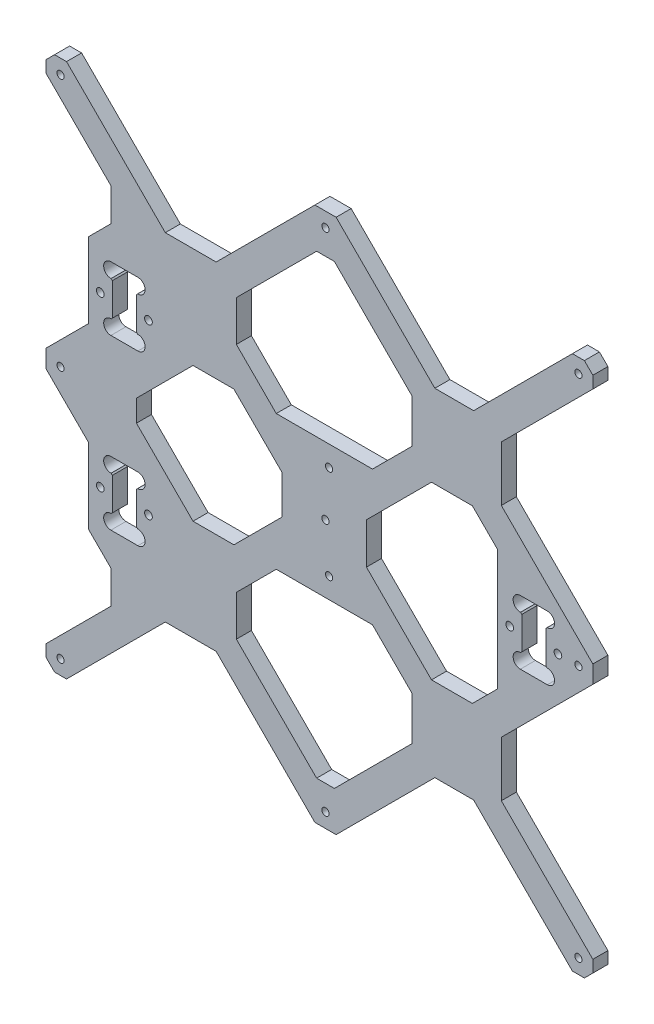
from build123d import *

# Parameters (mm, degrees)
MODEL_R             = 1.5
MODEL_R_2           = 1.6
BOSS_EXTRUDE1_DEPTH = 6.25


with BuildPart() as part:
    # Model → Boss-Extrude1 (new body)
    with BuildSketch(Plane.XY):
        Polygon((4.400116, 111), (45.400116, 70), (61.514718626, 70), (102.514718626, 111), (107.485169777, 111), (111, 107.485169777), (111, 102.514718626), (73, 64.514718626), (73, 41.666961), (111, 3.666961), (111, -3.666961), (73, -41.666961), (73, -64.514718626), (111, -102.514718626), (111, -107.485169777), (107.485169777, -111), (102.514718626, -111), (61.514718626, -70), (45.400116, -70), (4.400116, -111), (-4.400116, -111), (-45.400116, -70), (-66.514718626, -70), (-107.514718626, -111), (-112.485169777, -111), (-116, -107.485169777), (-116, -102.514718626), (-89, -75.514718626), (-89, -62), (-98.5, -52.5), (-98.5, -21.239105), (-116, -3.739105), (-116, 3.739105), (-98.5, 21.239105), (-98.5, 52.5), (-89, 62), (-89, 75.514718626), (-116, 102.514718626), (-116, 107.485169777), (-112.485169777, 111), (-107.514718626, 111), (-66.514718626, 70), (-45.400116, 70), (-4.400116, 111), align=None)
        with Locations((0, -105)):
            Circle(MODEL_R, mode=Mode.SUBTRACT)
        with Locations((0, 105)):
            Circle(MODEL_R, mode=Mode.SUBTRACT)
        with Locations((105, -105)):
            Circle(MODEL_R, mode=Mode.SUBTRACT)
        with Locations((-110, 105)):
            Circle(MODEL_R, mode=Mode.SUBTRACT)
        with Locations((105, 105)):
            Circle(MODEL_R, mode=Mode.SUBTRACT)
        with Locations((-110, 0)):
            Circle(MODEL_R, mode=Mode.SUBTRACT)
        Circle(MODEL_R, mode=Mode.SUBTRACT)
        with Locations((105, 0)):
            Circle(MODEL_R, mode=Mode.SUBTRACT)
        with Locations((76.5, 0)):
            Circle(MODEL_R_2, mode=Mode.SUBTRACT)
        with Locations((96.5, 0)):
            Circle(MODEL_R_2, mode=Mode.SUBTRACT)
        with Locations((-73.5, 35)):
            Circle(MODEL_R_2, mode=Mode.SUBTRACT)
        with Locations((-73.5, -35)):
            Circle(MODEL_R_2, mode=Mode.SUBTRACT)
        with Locations((-93.5, 35)):
            Circle(MODEL_R_2, mode=Mode.SUBTRACT)
        with Locations((-93.5, -35)):
            Circle(MODEL_R_2, mode=Mode.SUBTRACT)
        with Locations((-110, -105)):
            Circle(MODEL_R, mode=Mode.SUBTRACT)
        with Locations((1.5, -19.5)):
            Circle(MODEL_R, mode=Mode.SUBTRACT)
        with Locations((1.5, 19.5)):
            Circle(MODEL_R, mode=Mode.SUBTRACT)
        Polygon((-18, -7.97703218), (-38.02296782, -28), (-55.000029993, -28), (-78.5, -4.5), (-78.5, 4.5), (-55.000029993, 28), (-38.02296782, 28), (-18, 7.97703218), align=None, mode=Mode.SUBTRACT)
        Polygon((71.5, 25.014709), (60.98529, 35.529449), (44.014709, 35.529449), (17, 8.51474), (17, -8.51474), (44.014709, -35.529449), (60.98529, -35.529449), (71.5, -25.014709), align=None, mode=Mode.SUBTRACT)
        Polygon((-37, 61.415771), (-37, 44.566314), (-20.433686, 28), (19.51474, 28), (36, 44.48526), (36, 62.429580116), (3.682617, 94.746963116), (-3.682617, 94.733154), align=None, mode=Mode.SUBTRACT)
        Polygon((-37, -61.415771), (-37, -44.566314), (-20.433686, -28), (19.51474, -28), (36, -44.48526), (36, -62.429580116), (3.682617, -94.746963116), (-3.682617, -94.733154), align=None, mode=Mode.SUBTRACT)
        with BuildLine():
            Line((-78.499999987, 41.75), (-78.499999987, 28.25))
            Line((-78.499999987, 28.25), (-77.999999987, 27.75))
            Line((-77.999999987, 27.75), (-77.899999843, 27.75))
            ThreePointArc((-77.899999843, 27.75), (-74.899999843, 24.75), (-77.899999843, 21.75))
            Line((-77.899999843, 21.75), (-89.100000157, 21.75))
            ThreePointArc((-89.100000157, 21.75), (-92.100000157, 24.75), (-89.100000157, 27.75))
            Line((-89.100000157, 27.75), (-89.000000013, 27.75))
            Line((-89.000000013, 27.75), (-88.500000013, 28.25))
            Line((-88.500000013, 28.25), (-88.500000013, 41.75))
            Line((-88.500000013, 41.75), (-89.000000013, 42.25))
            Line((-89.000000013, 42.25), (-89.100000157, 42.25))
            ThreePointArc((-89.100000157, 42.25), (-92.100000157, 45.25), (-89.100000157, 48.25))
            Line((-89.100000157, 48.25), (-77.899999843, 48.25))
            ThreePointArc((-77.899999843, 48.25), (-74.899999843, 45.25), (-77.899999843, 42.25))
            Line((-77.899999843, 42.25), (-77.999999987, 42.25))
            Line((-77.999999987, 42.25), (-78.499999987, 41.75))
        make_face(mode=Mode.SUBTRACT)
        with BuildLine():
            Line((91.500000013, 6.75), (91.500000013, -6.75))
            Line((91.500000013, -6.75), (92.000000013, -7.25))
            Line((92.000000013, -7.25), (92.100000157, -7.25))
            ThreePointArc((92.100000157, -7.25), (95.100000157, -10.25), (92.100000157, -13.25))
            Line((92.100000157, -13.25), (80.899999843, -13.25))
            ThreePointArc((80.899999843, -13.25), (77.899999843, -10.25), (80.899999843, -7.25))
            Line((80.899999843, -7.25), (80.999999987, -7.25))
            Line((80.999999987, -7.25), (81.499999987, -6.75))
            Line((81.499999987, -6.75), (81.499999987, 6.75))
            Line((81.499999987, 6.75), (80.999999987, 7.25))
            Line((80.999999987, 7.25), (80.899999843, 7.25))
            ThreePointArc((80.899999843, 7.25), (77.899999843, 10.25), (80.899999843, 13.25))
            Line((80.899999843, 13.25), (92.100000157, 13.25))
            ThreePointArc((92.100000157, 13.25), (95.100000157, 10.25), (92.100000157, 7.25))
            Line((92.100000157, 7.25), (92.000000013, 7.25))
            Line((92.000000013, 7.25), (91.500000013, 6.75))
        make_face(mode=Mode.SUBTRACT)
        with BuildLine():
            Line((-78.499999987, -28.25), (-78.499999987, -41.75))
            Line((-78.499999987, -41.75), (-77.999999987, -42.25))
            Line((-77.999999987, -42.25), (-77.899999843, -42.25))
            ThreePointArc((-77.899999843, -42.25), (-74.899999843, -45.25), (-77.899999843, -48.25))
            Line((-77.899999843, -48.25), (-89.100000157, -48.25))
            ThreePointArc((-89.100000157, -48.25), (-92.100000157, -45.25), (-89.100000157, -42.25))
            Line((-89.100000157, -42.25), (-89.000000013, -42.25))
            Line((-89.000000013, -42.25), (-88.500000013, -41.75))
            Line((-88.500000013, -41.75), (-88.500000013, -28.25))
            Line((-88.500000013, -28.25), (-89.000000013, -27.75))
            Line((-89.000000013, -27.75), (-89.100000157, -27.75))
            ThreePointArc((-89.100000157, -27.75), (-92.100000157, -24.75), (-89.100000157, -21.75))
            Line((-89.100000157, -21.75), (-77.899999843, -21.75))
            ThreePointArc((-77.899999843, -21.75), (-74.899999843, -24.75), (-77.899999843, -27.75))
            Line((-77.899999843, -27.75), (-77.999999987, -27.75))
            Line((-77.999999987, -27.75), (-78.499999987, -28.25))
        make_face(mode=Mode.SUBTRACT)
    extrude(amount=BOSS_EXTRUDE1_DEPTH)


solid = part.part
